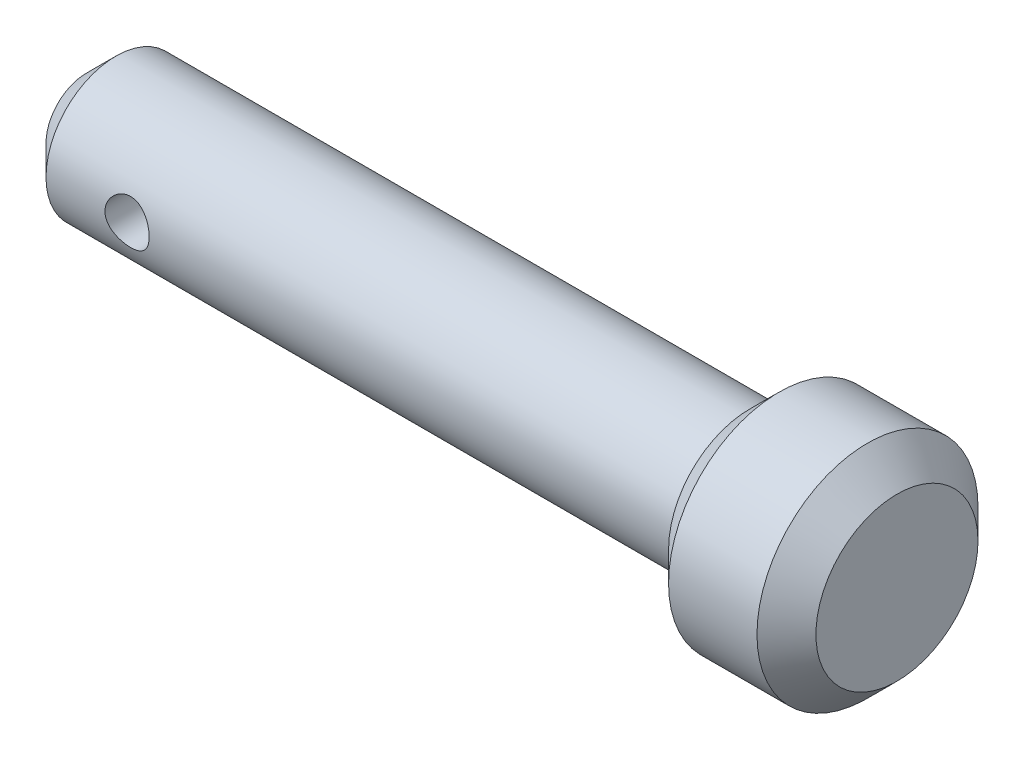
from build123d import *

# Parameters (mm, degrees)
CHAMFER1_SIZE           = 4
SKETCH2_R               = 3
CUT_EXTRUDE1_DEPTH      = 16
CUT_EXTRUDE1_DEPTH_BACK = 16


with BuildPart() as part:
    # Sketch1 → Revolve1 (revolve)
    with BuildSketch(Plane.XY):
        Polygon((0, 0), (0, -9.5), (90, -9.5), (90, -15), (110, -15), (110, 0), align=None)
    revolve(axis=Axis((0, 0, 0), (1, 0, 0)))

    # Chamfer1
    chamfer1_edges = [part.edges().sort_by_distance(p)[0] for p in [
        (0, 9.5, 0),
        (90, 15, 0),
        (110, 15, 0),
    ]]
    chamfer(chamfer1_edges, length=CHAMFER1_SIZE)

    # Sketch2 → Cut-Extrude1 (cut, two sides)
    with BuildSketch(Plane.XY) as cut_extrude1_sk:
        with Locations((15, 0)):
            Circle(SKETCH2_R)
    extrude(amount=CUT_EXTRUDE1_DEPTH, mode=Mode.SUBTRACT)
    extrude(cut_extrude1_sk.sketch, amount=-CUT_EXTRUDE1_DEPTH_BACK, mode=Mode.SUBTRACT)


solid = part.part
